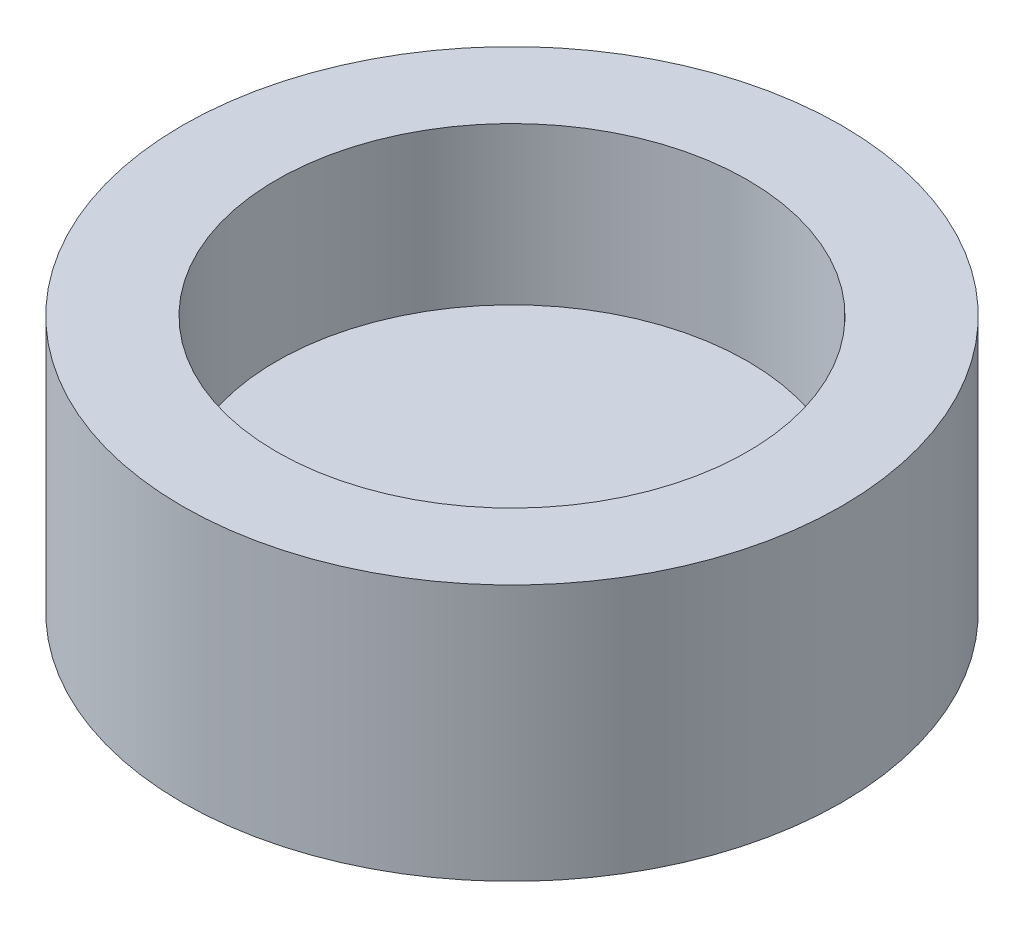
from build123d import *

# Parameters (mm, degrees)
SKETCH1_R           = 10.5
BOSS_EXTRUDE1_DEPTH = 8.17408016
SKETCH2_W           = 7.5
SKETCH2_H           = 5


with BuildPart() as part:
    # Sketch1 → Boss-Extrude1 (new body)
    with BuildSketch(Plane(origin=(0, 0, 0), x_dir=(1, 0, 0), z_dir=(0, 1, 0))):
        Circle(SKETCH1_R)
    extrude(amount=BOSS_EXTRUDE1_DEPTH)

    # Sketch2 → Cut-Revolve2 (revolve, cut)
    with BuildSketch(Plane(origin=(0, 0, 0), x_dir=(0, 0, -1), z_dir=(1, 0, 0))):
        with Locations((3.75, 5.67408016)):
            Rectangle(SKETCH2_W, SKETCH2_H)
    revolve(axis=Axis((0, 0.049098768, 0), (0, 1, 0)), mode=Mode.SUBTRACT)


solid = part.part
